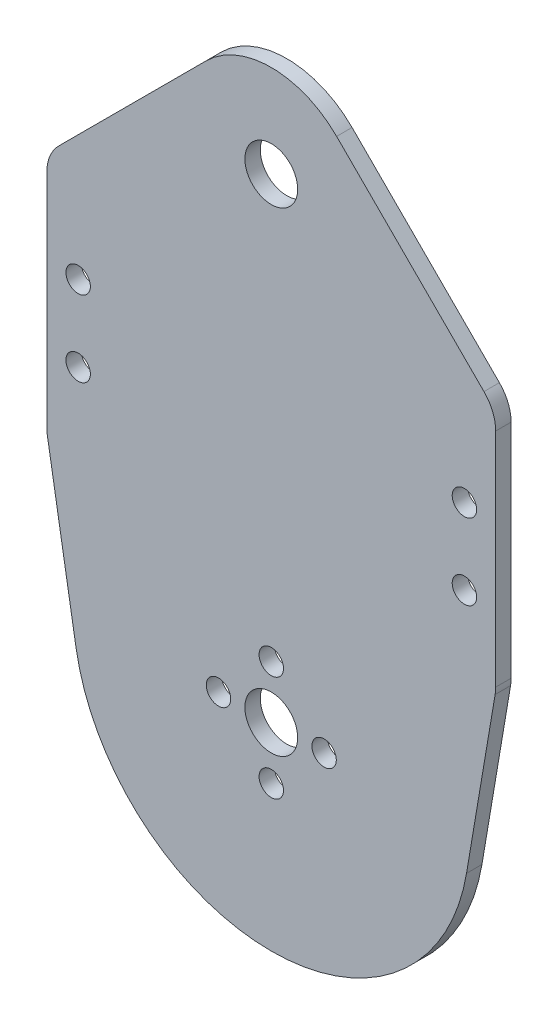
from build123d import *

# Parameters (mm, degrees)
SKETCH1_R           = 4
SKETCH1_R_2         = 1.85
BOSS_EXTRUDE1_DEPTH = 2.3368


with BuildPart() as part:
    # Sketch1 → Boss-Extrude1 (new body)
    with BuildSketch(Plane.XY):
        with BuildLine():
            Line((-34, 21.640538448), (-34, 55.247304326))
            ThreePointArc((-34, 55.247304326), (-33.538424872, 57.567799195), (-32.223970118, 59.535019756))
            Line((-32.223970118, 59.535019756), (-9.899494937, 81.859494937))
            ThreePointArc((-9.899494937, 81.859494937), (0, 85.96), (9.899494937, 81.859494937))
            Line((9.899494937, 81.859494937), (32.223970118, 59.535019756))
            ThreePointArc((32.223970118, 59.535019756), (33.538424872, 57.567799195), (34, 55.247304326))
            Line((34, 55.247304326), (34, 21.640538448))
            ThreePointArc((34, 21.640538448), (33.978735385, 21.133158673), (33.915090683, 20.629337502))
            Line((33.915090683, 20.629337502), (29.579916475, -5.002853321))
            ThreePointArc((29.579916475, -5.002853321), (0, -30), (-29.579916475, -5.002853321))
            Line((-29.579916475, -5.002853321), (-33.915090683, 20.629337502))
            ThreePointArc((-33.915090683, 20.629337502), (-33.978735385, 21.133158673), (-34, 21.640538448))
        make_face()
        Circle(SKETCH1_R, mode=Mode.SUBTRACT)
        with Locations((0, 8)):
            Circle(SKETCH1_R_2, mode=Mode.SUBTRACT)
        with Locations((-8, 0)):
            Circle(SKETCH1_R_2, mode=Mode.SUBTRACT)
        with Locations((0, -8)):
            Circle(SKETCH1_R_2, mode=Mode.SUBTRACT)
        with Locations((8, 0)):
            Circle(SKETCH1_R_2, mode=Mode.SUBTRACT)
        with Locations((0, 71.96)):
            Circle(SKETCH1_R, mode=Mode.SUBTRACT)
        with Locations((29.2625, 43.5)):
            Circle(SKETCH1_R_2, mode=Mode.SUBTRACT)
        with Locations((29.2625, 32)):
            Circle(SKETCH1_R_2, mode=Mode.SUBTRACT)
        with Locations((-29.2625, 43.5)):
            Circle(SKETCH1_R_2, mode=Mode.SUBTRACT)
        with Locations((-29.2625, 32)):
            Circle(SKETCH1_R_2, mode=Mode.SUBTRACT)
    extrude(amount=BOSS_EXTRUDE1_DEPTH)


solid = part.part
